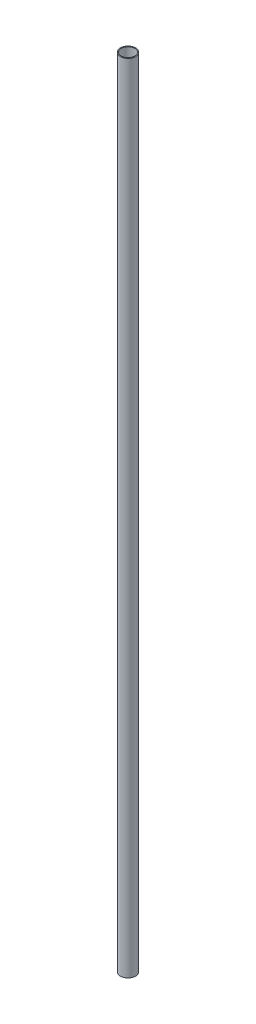
from build123d import *

# Parameters (mm, degrees)
SKETCH1_R           = 8.9662
SKETCH1_R_2         = 7.8994
BOSS_EXTRUDE1_DEPTH = 939.8


with BuildPart() as part:
    # Sketch1 → Boss-Extrude1 (new body)
    with BuildSketch(Plane(origin=(0, 0, 0), x_dir=(1, 0, 0), z_dir=(0, 1, 0))):
        Circle(SKETCH1_R)
        Circle(SKETCH1_R_2, mode=Mode.SUBTRACT)
    extrude(amount=-BOSS_EXTRUDE1_DEPTH)


solid = part.part
